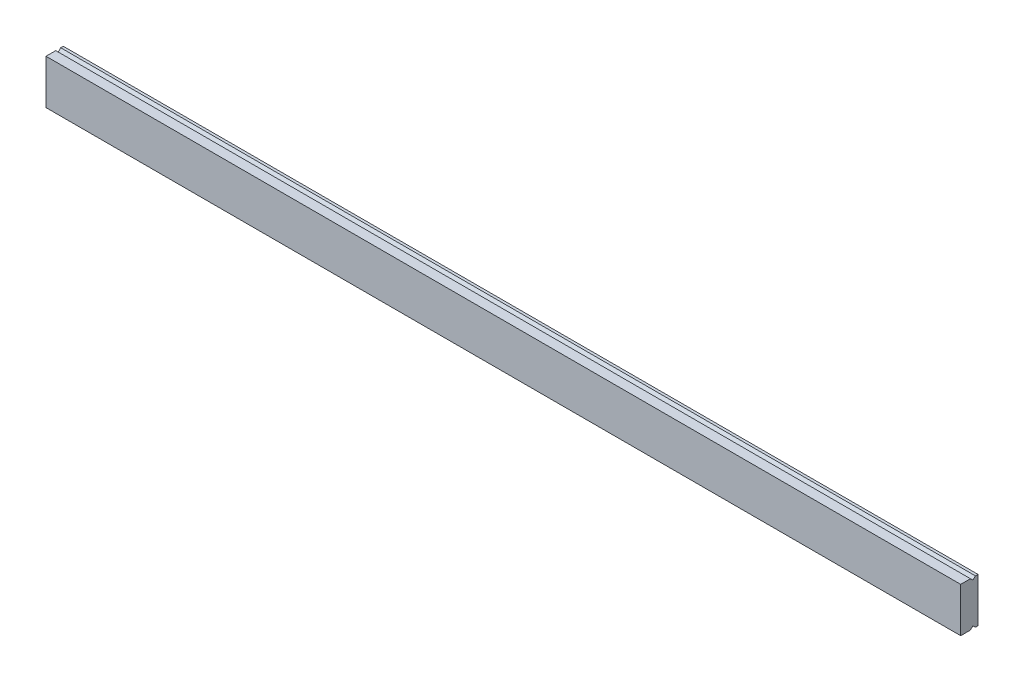
from build123d import *

# Parameters (mm, degrees)
EXTRUDE_1_DEPTH = 370


with BuildPart() as part:
    # 草图1 → 凸台-拉伸1 (new body)
    with BuildSketch(Plane(origin=(95, 0, 0), x_dir=(0, -1, 0), z_dir=(-1, 0, 0))):
        Polygon((-249, 463), (-231, 463), (-231, 464.05), (-232, 465.05), (-231, 466.05), (-231, 470), (-249, 470), (-249, 466.05), (-248, 465.05), (-249, 464.05), align=None)
    extrude(amount=-EXTRUDE_1_DEPTH)


solid = part.part
